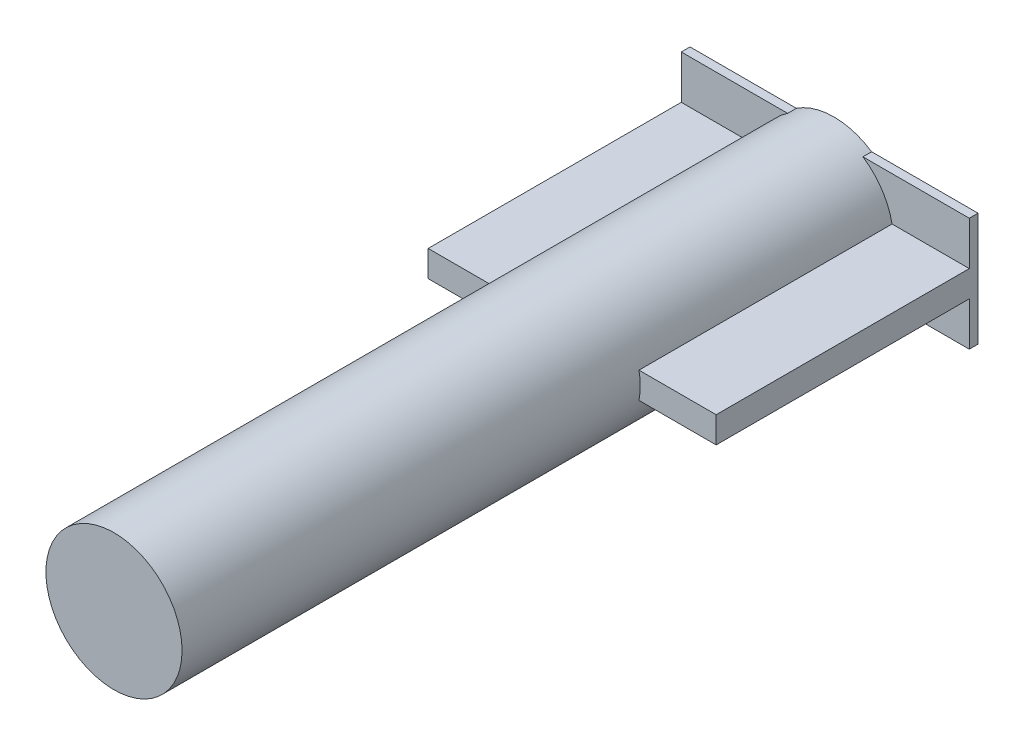
from build123d import *

# Parameters (mm, degrees)
SKETCH1_R           = 7.8
BOSS_EXTRUDE1_DEPTH = 82.5
SKETCH2_W           = 33
SKETCH2_H           = 13
BOSS_EXTRUDE2_DEPTH = 1
SKETCH3_W           = 33
SKETCH3_H           = 3
BOSS_EXTRUDE3_DEPTH = 30


with BuildPart() as part:
    # Sketch1 → Boss-Extrude1 (new body)
    with BuildSketch(Plane.XY):
        Circle(SKETCH1_R)
    extrude(amount=BOSS_EXTRUDE1_DEPTH)

    # Sketch2 → Boss-Extrude2 (add)
    with BuildSketch(Plane(origin=(0, 0, 0), x_dir=(-1, 0, 0), z_dir=(0, 0, -1))):
        Rectangle(SKETCH2_W, SKETCH2_H)
    extrude(amount=-BOSS_EXTRUDE2_DEPTH)

    # Sketch3 → Boss-Extrude3 (add)
    with BuildSketch(Plane(origin=(0, 0, 0), x_dir=(-1, 0, 0), z_dir=(0, 0, -1))):
        Rectangle(SKETCH3_W, SKETCH3_H)
    extrude(amount=-BOSS_EXTRUDE3_DEPTH)


solid = part.part
